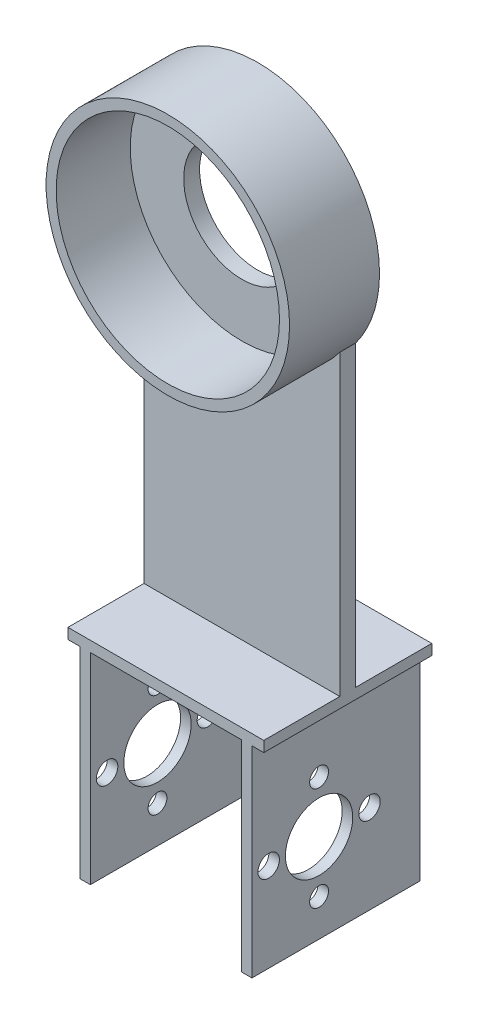
from build123d import *

# Parameters (mm, degrees)
SKETCH1_W                = 2
SKETCH1_H                = 31.74
BOSS_EXTRUDE1_DEPTH      = 40
BOSS_EXTRUDE1_2_DEPTH    = 40
SKETCH2_W                = 37
SKETCH2_H                = 31.74
BOSS_EXTRUDE3_DEPTH      = 2
SKETCH8_W                = 37
SKETCH8_H                = 3
BOSS_EXTRUDE4_DEPTH      = 70
SKETCH20_R               = 6.36
SKETCH20_R_2             = 1.78
SKETCH20_R_3             = 2.03
CUT_EXTRUDE4_DEPTH       = 3.24
CUT_EXTRUDE4_DEPTH_BACK  = 35.76
SKETCH23_R               = 23
BOSS_EXTRUDE6_DEPTH      = 14
BOSS_EXTRUDE6_DEPTH_BACK = 3
SKETCH25_R               = 21.1
CUT_EXTRUDE5_DEPTH       = 14
SKETCH26_R               = 11
CUT_EXTRUDE6_DEPTH       = 15.37
CUT_EXTRUDE6_DEPTH_BACK  = 18.37


with BuildPart() as part:
    # Sketch1 → Boss-Extrude1 (new body)
    with BuildSketch(Plane(origin=(0, 0, 0), x_dir=(1, 0, 0), z_dir=(0, 1, 0))):
        with Locations((-2.074327578, -14.662349727)):
            Rectangle(SKETCH1_W, SKETCH1_H)
    extrude(amount=BOSS_EXTRUDE1_DEPTH)



with BuildPart() as body_2:
    # Sketch1 → Boss-Extrude1 2 (new body)
    with BuildSketch(Plane(origin=(0, 0, 0), x_dir=(1, 0, 0), z_dir=(0, 1, 0))):
        with Locations((28.453672422, -14.662349727)):
            Rectangle(SKETCH1_W, SKETCH1_H)
    extrude(amount=BOSS_EXTRUDE1_2_DEPTH)


with BuildPart() as part_1:
    add(part.part)

    add(body_2.part)  # Boss-Extrude3 merges body 2
    # Sketch2 → Boss-Extrude3 (add)
    with BuildSketch(Plane(origin=(0, 40, 0), x_dir=(1, 0, 0), z_dir=(0, 1, 0))):
        with Locations((13.193672422, -14.662349727)):
            Rectangle(SKETCH2_W, SKETCH2_H)
    extrude(amount=-BOSS_EXTRUDE3_DEPTH)

    # Sketch8 → Boss-Extrude4 (add)
    with BuildSketch(Plane(origin=(0, 40, 0), x_dir=(1, 0, 0), z_dir=(0, 1, 0))):
        with Locations((13.193672422, -14.662349727)):
            Rectangle(SKETCH8_W, SKETCH8_H)
    extrude(amount=BOSS_EXTRUDE4_DEPTH)

    # Sketch20 → Cut-Extrude4 (cut, two sides)
    with BuildSketch(Plane(origin=(29.453672422, 0, 0), x_dir=(0, 0, -1), z_dir=(1, 0, 0))) as cut_extrude4_sk:
        with Locations((-17.842349727, 16.779878139)):
            Circle(SKETCH20_R)
        with Locations((-17.842349727, 26.558878139)):
            Circle(SKETCH20_R_2)
        with Locations((-17.842349727, 7.000878139)):
            Circle(SKETCH20_R_2)
        with Locations((-27.367349727, 16.779878139)):
            Circle(SKETCH20_R_3)
        with Locations((-8.317349727, 16.779878139)):
            Circle(SKETCH20_R_3)
    extrude(amount=CUT_EXTRUDE4_DEPTH, mode=Mode.SUBTRACT)
    extrude(cut_extrude4_sk.sketch, amount=-CUT_EXTRUDE4_DEPTH_BACK, mode=Mode.SUBTRACT)

    # Sketch23 → Boss-Extrude6 (add, two sides)
    with BuildSketch(Plane.XY.offset(16.162349727)) as boss_extrude6_sk:
        with Locations((13.193672422, 110)):
            Circle(SKETCH23_R)
    extrude(amount=BOSS_EXTRUDE6_DEPTH)
    extrude(boss_extrude6_sk.sketch, amount=-BOSS_EXTRUDE6_DEPTH_BACK)

    # Sketch25 → Cut-Extrude5 (cut)
    with BuildSketch(Plane.XY.offset(30.162349727)):
        with Locations((13.193672422, 110)):
            Circle(SKETCH25_R)
    extrude(amount=-CUT_EXTRUDE5_DEPTH, mode=Mode.SUBTRACT)

    # Sketch26 → Cut-Extrude6 (cut, two sides)
    with BuildSketch(Plane.XY.offset(16.162349727)) as cut_extrude6_sk:
        with Locations((13.193672422, 110)):
            Circle(SKETCH26_R)
    extrude(amount=CUT_EXTRUDE6_DEPTH, mode=Mode.SUBTRACT)
    extrude(cut_extrude6_sk.sketch, amount=-CUT_EXTRUDE6_DEPTH_BACK, mode=Mode.SUBTRACT)


solid = part_1.part
